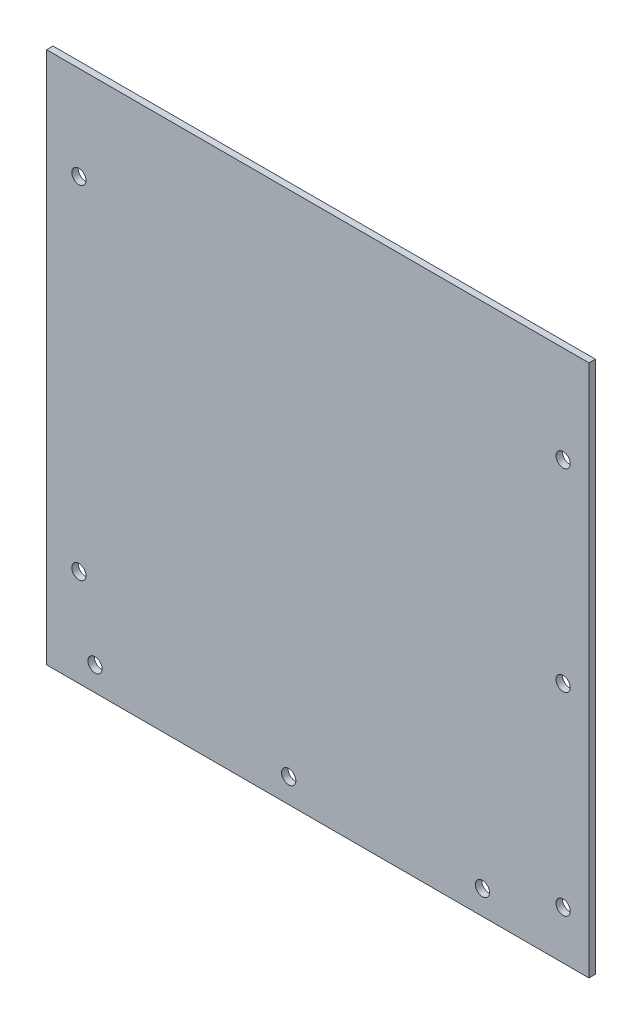
from build123d import *

# Parameters (mm, degrees)
SKETCH_1_W          = 168
SKETCH_1_H          = 167
EXTRUDE_1_DEPTH     = 2
SKETCH_2_R          = 2.2
CUT_EXTRUDE_1_DEPTH = 2
SKETCH_3_W          = 168
SKETCH_3_H          = 2
CUT_EXTRUDE_2_DEPTH = 2
SKETCH_4_R          = 2.2
CUT_EXTRUDE_3_DEPTH = 2
SKETCH_6_R          = 2.2
CUT_EXTRUDE_5_DEPTH = 10
SKETCH_7_R          = 2.2
CUT_EXTRUDE_6_DEPTH = 10


with BuildPart() as part:
    # ｽｹｯﾁ1 → ﾎﾞｽ - 押し出し1 (new body)
    with BuildSketch(Plane.XY):
        Rectangle(SKETCH_1_W, SKETCH_1_H)
    extrude(amount=EXTRUDE_1_DEPTH)

    # ｽｹｯﾁ2 → ｶｯﾄ - 押し出し1 (cut)
    with BuildSketch(Plane.XY.offset(2)):
        with Locations((76, -68.5)):
            Circle(SKETCH_2_R)
        with Locations((76, -8.5)):
            Circle(SKETCH_2_R)
        with Locations((76, 51.5)):
            Circle(SKETCH_2_R)
    extrude(amount=-CUT_EXTRUDE_1_DEPTH, mode=Mode.SUBTRACT)

    # ｽｹｯﾁ3 → ｶｯﾄ - 押し出し2 (cut)
    with BuildSketch(Plane(origin=(0, 83.5, 0), x_dir=(1, 0, 0), z_dir=(0, 1, 0))):
        with Locations((0, -1)):
            Rectangle(SKETCH_3_W, SKETCH_3_H)
    extrude(amount=-CUT_EXTRUDE_2_DEPTH, mode=Mode.SUBTRACT)

    # ｽｹｯﾁ4 → ｶｯﾄ - 押し出し3 (cut)
    with BuildSketch(Plane.XY.offset(2)):
        with BuildLine():
            ThreePointArc((-6.8, -76), (-9, -73.8), (-11.2, -76))
            Line((-11.2, -76), (-9, -76))
            Line((-9, -76), (-6.8, -76))
        make_face()
        with BuildLine():
            Line((-9, -76), (-11.2, -76))
            ThreePointArc((-11.2, -76), (-9, -78.2), (-6.8, -76))
            Line((-6.8, -76), (-9, -76))
        make_face()
        with BuildLine():
            ThreePointArc((-66.8, -76), (-69, -73.8), (-71.2, -76))
            Line((-71.2, -76), (-69, -76))
            Line((-69, -76), (-66.8, -76))
        make_face()
        with BuildLine():
            Line((-69, -76), (-71.2, -76))
            ThreePointArc((-71.2, -76), (-69, -78.2), (-66.8, -76))
            Line((-66.8, -76), (-69, -76))
        make_face()
        with Locations((51, -76)):
            Circle(SKETCH_4_R)
    extrude(amount=-CUT_EXTRUDE_3_DEPTH, mode=Mode.SUBTRACT)

    # ｽｹｯﾁ6 → ｶｯﾄ - 押し出し5 (cut)
    with BuildSketch(Plane(origin=(0, 0, 0), x_dir=(-1, 0, 0), z_dir=(0, 0, -1))):
        with Locations((74, 52.5)):
            Circle(SKETCH_6_R)
    extrude(amount=-CUT_EXTRUDE_5_DEPTH, mode=Mode.SUBTRACT)

    # ｽｹｯﾁ7 → ｶｯﾄ - 押し出し6 (cut)
    with BuildSketch(Plane(origin=(0, 0, 0), x_dir=(-1, 0, 0), z_dir=(0, 0, -1))):
        with Locations((74, -53.5)):
            Circle(SKETCH_7_R)
    extrude(amount=-CUT_EXTRUDE_6_DEPTH, mode=Mode.SUBTRACT)


solid = part.part
